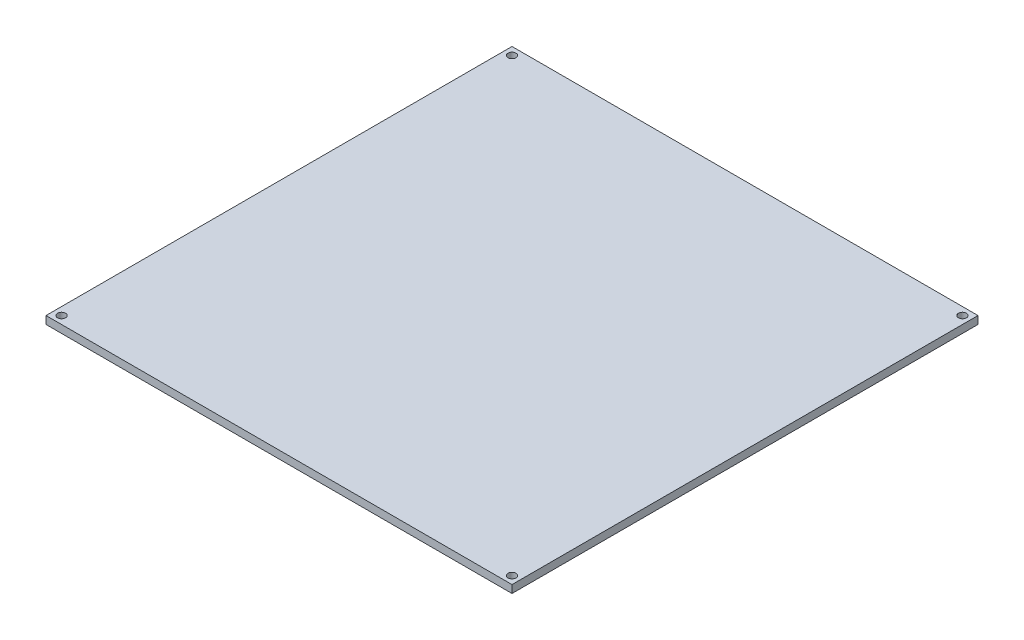
from build123d import *

# Parameters (mm, degrees)
SKETCH_3_R      = 1.55
EXTRUDE_2_DEPTH = 3


with BuildPart() as part:
    # 草图3 → 凸台-拉伸2 (new body)
    with BuildSketch(Plane(origin=(0, 0, 0), x_dir=(1, 0, 0), z_dir=(0, 1, 0))):
        Polygon((195, 190), (195, 195), (192, 195), (190, 195), (175, 195), (35, 195), (20, 195), (18, 195), (15, 195), (15, 190), (15, 175), (15, 35), (15, 20), (15, 15), (18, 15), (20, 15), (175, 15), (190, 15), (192, 15), (195, 15), (195, 20), (195, 35), (195, 175), align=None)
        with Locations((18, 18)):
            Circle(SKETCH_3_R, mode=Mode.SUBTRACT)
        with Locations((192, 18)):
            Circle(SKETCH_3_R, mode=Mode.SUBTRACT)
        with Locations((18, 192)):
            Circle(SKETCH_3_R, mode=Mode.SUBTRACT)
        with Locations((192, 192)):
            Circle(SKETCH_3_R, mode=Mode.SUBTRACT)
    extrude(amount=EXTRUDE_2_DEPTH)


solid = part.part
